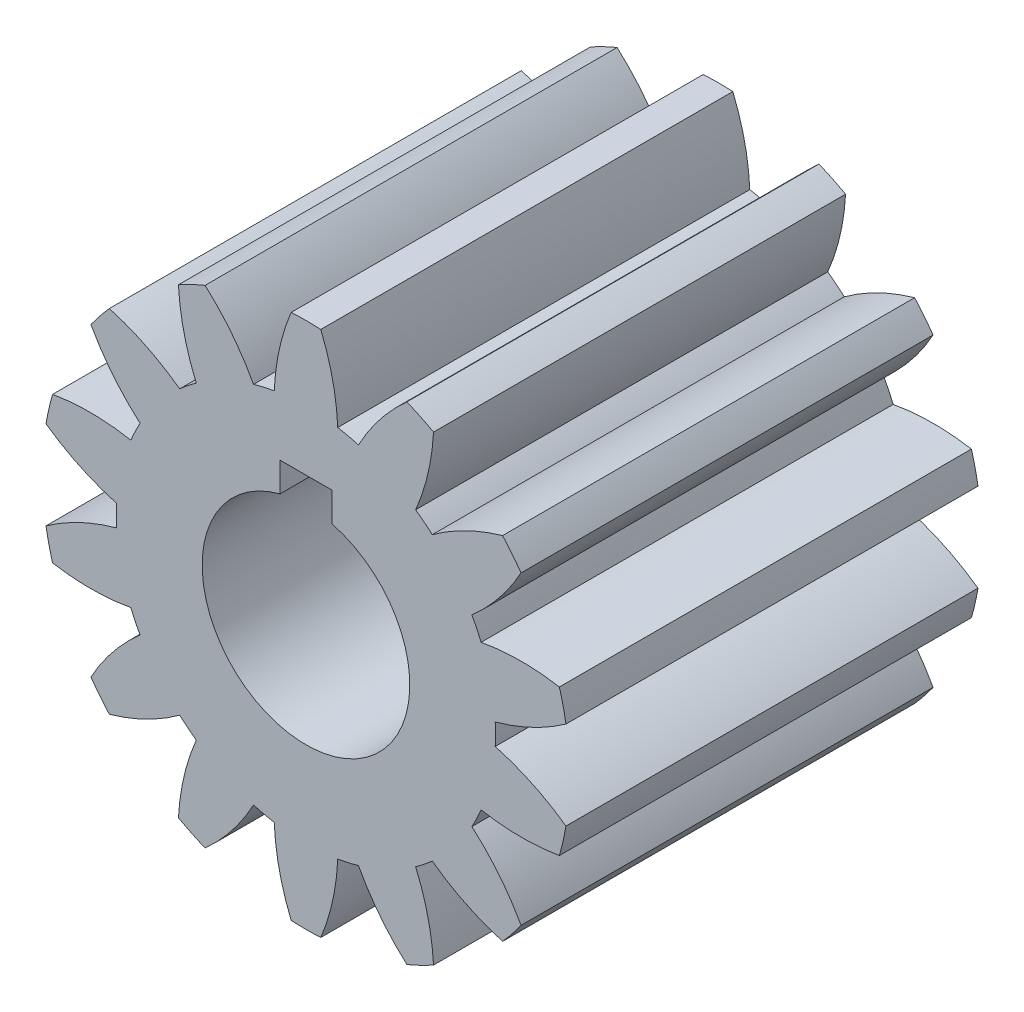
from build123d import *

# Parameters (mm, degrees)
BOSS_EXTRUDE1_DEPTH = 15.875


with BuildPart() as part:
    # Sketch1 → Boss-Extrude1 (new body)
    with BuildSketch(Plane.XY.offset(15.875)):
        with BuildLine():
            ThreePointArc((-3.888063673, 9.38661605), (-4.408258789, 9.153843698), (-4.914583893, 8.892269967))
            ThreePointArc((-4.914583893, 8.892269967), (-4.69950786, 7.393612219), (-4.22574714, 5.955633246))
            ThreePointArc((-4.22574714, 5.955633246), (-4.553034278, 5.709324401), (-4.865995885, 5.445051909))
            ThreePointArc((-4.865995885, 5.445051909), (-6.162500046, 6.226914882), (-7.575724395, 6.770081232))
            ThreePointArc((-7.575724395, 6.770081232), (-7.943407862, 6.334656387), (-8.286098429, 5.879300369))
            ThreePointArc((-8.286098429, 5.879300369), (-7.442078391, 4.622374388), (-6.391319038, 3.532357173))
            ThreePointArc((-6.391319038, 3.532357173), (-6.579325158, 3.168436005), (-6.746630286, 2.794545765))
            ThreePointArc((-6.746630286, 2.794545765), (-8.253977802, 2.93644789), (-9.762919991, 2.812648796))
            ThreePointArc((-9.762919991, 2.812648796), (-9.905267588, 2.260812689), (-10.016449548, 1.701863229))
            ThreePointArc((-10.016449548, 1.701863229), (-8.710654026, 0.93561862), (-7.291011817, 0.409454441))
            ThreePointArc((-7.291011817, 0.409454441), (-7.3025, 0), (-7.291011817, -0.409454441))
            ThreePointArc((-7.291011817, -0.409454441), (-8.710654026, -0.93561862), (-10.016449548, -1.701863229))
            ThreePointArc((-10.016449548, -1.701863229), (-9.905267588, -2.260812689), (-9.762919991, -2.812648796))
            ThreePointArc((-9.762919991, -2.812648796), (-8.253977802, -2.93644789), (-6.746630286, -2.794545765))
            ThreePointArc((-6.746630286, -2.794545765), (-6.579325158, -3.168436005), (-6.391319038, -3.532357173))
            ThreePointArc((-6.391319038, -3.532357173), (-7.442078391, -4.622374388), (-8.286098429, -5.879300369))
            ThreePointArc((-8.286098429, -5.879300369), (-7.943407862, -6.334656387), (-7.575724395, -6.770081232))
            ThreePointArc((-7.575724395, -6.770081232), (-6.162500046, -6.226914882), (-4.865995885, -5.445051909))
            ThreePointArc((-4.865995885, -5.445051909), (-4.553034278, -5.709324401), (-4.22574714, -5.955633246))
            ThreePointArc((-4.22574714, -5.955633246), (-4.69950786, -7.393612219), (-4.914583893, -8.892269967))
            ThreePointArc((-4.914583893, -8.892269967), (-4.408258789, -9.153843698), (-3.888063673, -9.38661605))
            ThreePointArc((-3.888063673, -9.38661605), (-2.850463577, -8.284065014), (-2.021591322, -7.017098744))
            ThreePointArc((-2.021591322, -7.017098744), (-1.62495912, -7.119411079), (-1.223214196, -7.199323113))
            ThreePointArc((-1.223214196, -7.199323113), (-1.026142161, -8.700454472), (-0.569675744, -10.144016441))
            ThreePointArc((-0.569675744, -10.144016441), (0, -10.16), (0.569675744, -10.144016441))
            ThreePointArc((0.569675744, -10.144016441), (1.026142161, -8.700454472), (1.223214196, -7.199323113))
            ThreePointArc((1.223214196, -7.199323113), (1.62495912, -7.119411079), (2.021591322, -7.017098744))
            ThreePointArc((2.021591322, -7.017098744), (2.850463577, -8.284065014), (3.888063673, -9.38661605))
            ThreePointArc((3.888063673, -9.38661605), (4.408258789, -9.153843698), (4.914583893, -8.892269967))
            ThreePointArc((4.914583893, -8.892269967), (4.69950786, -7.393612219), (4.22574714, -5.955633246))
            ThreePointArc((4.22574714, -5.955633246), (4.553034278, -5.709324401), (4.865995885, -5.445051909))
            ThreePointArc((4.865995885, -5.445051909), (6.162500046, -6.226914882), (7.575724395, -6.770081232))
            ThreePointArc((7.575724395, -6.770081232), (7.943407862, -6.334656387), (8.286098429, -5.879300369))
            ThreePointArc((8.286098429, -5.879300369), (7.442078391, -4.622374388), (6.391319038, -3.532357173))
            ThreePointArc((6.391319038, -3.532357173), (6.579325158, -3.168436005), (6.746630286, -2.794545765))
            ThreePointArc((6.746630286, -2.794545765), (8.253977802, -2.93644789), (9.762919991, -2.812648796))
            ThreePointArc((9.762919991, -2.812648796), (9.905267588, -2.260812689), (10.016449548, -1.701863229))
            ThreePointArc((10.016449548, -1.701863229), (8.710654026, -0.93561862), (7.291011817, -0.409454441))
            ThreePointArc((7.291011817, -0.409454441), (7.3025, 0), (7.291011817, 0.409454441))
            ThreePointArc((7.291011817, 0.409454441), (8.710654026, 0.93561862), (10.016449548, 1.701863229))
            ThreePointArc((10.016449548, 1.701863229), (9.905267588, 2.260812689), (9.762919991, 2.812648796))
            ThreePointArc((9.762919991, 2.812648796), (8.253977802, 2.93644789), (6.746630286, 2.794545765))
            ThreePointArc((6.746630286, 2.794545765), (6.579325158, 3.168436005), (6.391319038, 3.532357173))
            ThreePointArc((6.391319038, 3.532357173), (7.442078391, 4.622374388), (8.286098429, 5.879300369))
            ThreePointArc((8.286098429, 5.879300369), (7.943407862, 6.334656387), (7.575724395, 6.770081232))
            ThreePointArc((7.575724395, 6.770081232), (6.162500046, 6.226914882), (4.865995885, 5.445051909))
            ThreePointArc((4.865995885, 5.445051909), (4.553034278, 5.709324401), (4.22574714, 5.955633246))
            ThreePointArc((4.22574714, 5.955633246), (4.69950786, 7.393612219), (4.914583893, 8.892269967))
            ThreePointArc((4.914583893, 8.892269967), (4.408258789, 9.153843698), (3.888063673, 9.38661605))
            ThreePointArc((3.888063673, 9.38661605), (2.850463577, 8.284065014), (2.021591322, 7.017098744))
            ThreePointArc((2.021591322, 7.017098744), (1.62495912, 7.119411079), (1.223214196, 7.199323113))
            ThreePointArc((1.223214196, 7.199323113), (1.026142161, 8.700454472), (0.569675744, 10.144016441))
            ThreePointArc((0.569675744, 10.144016441), (0, 10.16), (-0.569675744, 10.144016441))
            ThreePointArc((-0.569675744, 10.144016441), (-1.026142161, 8.700454472), (-1.223214196, 7.199323113))
            ThreePointArc((-1.223214196, 7.199323113), (-1.62495912, 7.119411079), (-2.021591322, 7.017098744))
            ThreePointArc((-2.021591322, 7.017098744), (-2.850463577, 8.284065014), (-3.888063673, 9.38661605))
        make_face()
        with BuildLine():
            Line((1, 5), (1, 3.872983346))
            ThreePointArc((1, 3.872983346), (0, -4), (-1, 3.872983346))
            Line((-1, 3.872983346), (-1, 5))
            Line((-1, 5), (1, 5))
        make_face(mode=Mode.SUBTRACT)
    extrude(amount=-BOSS_EXTRUDE1_DEPTH)


solid = part.part
